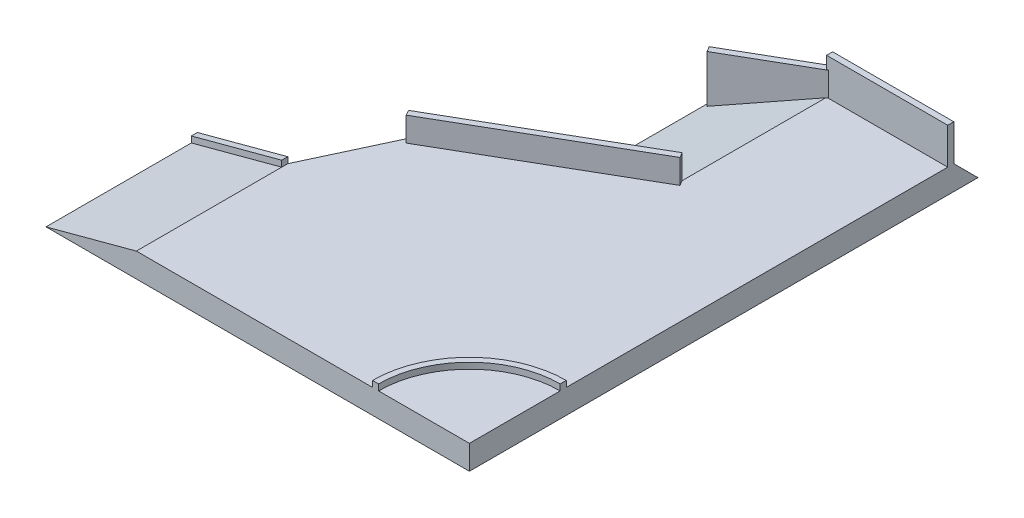
from build123d import *

# Parameters (mm, degrees)
EXTRUDE_1_DEPTH              = 400
EXTRUDE_2_DEPTH              = 100
SKETCH_3_W                   = 2000
SKETCH_3_H                   = 100
EXTRUDE_3_DEPTH              = 600
EXTRUDE_4_DEPTH              = 400
EXTRUDE_5_DEPTH              = 2500
EXTRUDE_6_DEPTH              = 100
EXTRUDE_7_REACH              = 6699.625
EXTRUDE_8_REACH              = 9240.058
EXTRUDE_10_REACH             = 8119.853
EXTRUDE_11_DEPTH             = 1492.820323
EXTRUDE_11_DIRECTION_2_REACH = 8492.6
SKETCH_12_W                  = 1492.820323027
SKETCH_12_H                  = 800
EXTRUDE_12_DEPTH             = 100


with BuildPart() as part:
    # 草图1 → 凸台-拉伸1 (new body)
    with BuildSketch(Plane(origin=(0, 0, 0), x_dir=(1, 0, 0), z_dir=(0, 1, 0))):
        Polygon((-2750, -1500), (-2116.072607389, -140.538319445), (750, 1514.189471948), (750, 4000), (2750, 4000), (2750, -4000), (-2750, -4000), align=None)
    extrude(amount=EXTRUDE_1_DEPTH)

    # 草图2 → 凸台-拉伸2 (add)
    with BuildSketch(Plane(origin=(0, 400, 0), x_dir=(1, 0, 0), z_dir=(0, 1, 0))):
        with BuildLine():
            Line((1150, -4000), (1250, -4000))
            ThreePointArc((1250, -4000), (1689.33982822, -2939.33982822), (2750, -2500))
            Line((2750, -2500), (2750, -2400))
            ThreePointArc((2750, -2400), (1618.629150102, -2868.629150102), (1150, -4000))
        make_face()
    extrude(amount=EXTRUDE_2_DEPTH)

    # 草图3 → 凸台-拉伸3 (add)
    with BuildSketch(Plane(origin=(0, 400, 0), x_dir=(1, 0, 0), z_dir=(0, 1, 0))):
        with Locations((1750, 3950)):
            Rectangle(SKETCH_3_W, SKETCH_3_H)
    extrude(amount=EXTRUDE_3_DEPTH)

    # 草图4 → 凸台-拉伸4 (add)
    with BuildSketch(Plane(origin=(0, 400, 0), x_dir=(1, 0, 0), z_dir=(0, 1, 0))):
        Polygon((750, 1514.189471948), (-2116.072607389, -140.538319445), (-2066.072607389, -227.140859823), (800, 1427.58693157), align=None)
    extrude(amount=EXTRUDE_4_DEPTH)

    # 草图5 → 凸台-拉伸5 (add)
    with BuildSketch(Plane.XY.offset(4000)):
        Polygon((-2750, 400), (-2750, 0), (-4242.820323028, 0), align=None)
    extrude(amount=-EXTRUDE_5_DEPTH)

    # 草图6 → 凸台-拉伸6 (add)
    with BuildSketch(Plane(origin=(0, 0, 1500), x_dir=(-1, 0, 0), z_dir=(0, 0, -1))):
        Polygon((2750, 400), (4242.820323028, 0), (4242.820323028, 100), (2750, 500), align=None)
    extrude(amount=-EXTRUDE_6_DEPTH)

    # 凸台-拉伸7: up to this plane
    extrude_7_end = Plane(origin=(750, 400, -1514.189471948), z_dir=(1, 0, 0))
    # 草图7 → 凸台-拉伸7 (add, up to the surface)
    with BuildSketch(Plane(origin=(-1647.909332964, 0, 951.420896987), x_dir=(0.4999999999999981, 0, 0.8660254037844398), z_dir=(-0.8660254037844398, 0, 0.49999999999999817)), mode=Mode.PRIVATE) as extrude_7_sk1:
        Polygon((-936.32654885, 0), (-1336.32654885, 0), (-936.32654885, 400), align=None)
    extrude_7_tool1 = split(extrude(extrude_7_sk1.sketch, amount=-EXTRUDE_7_REACH, mode=Mode.PRIVATE), bisect_by=extrude_7_end, keep=Keep.BOTH, mode=Mode.PRIVATE)
    add(extrude_7_tool1.solids().sort_by_distance((-2182.739274, 133.333333, 25.068266))[0])

    # 凸台-拉伸8: up to this plane
    extrude_8_end = Plane(origin=(499800, 0, -290102.721526381), z_dir=(-0.3535533905932706, 0.7071067811865511, -0.6123724356957922))
    # 草图8 → 凸台-拉伸8 (add, up to the surface)
    with BuildSketch(Plane(origin=(-1544.550807569, 0, -2675.240473581), x_dir=(0, -1, 0), z_dir=(0.49999999999999495, 0, 0.8660254037844416)), mode=Mode.PRIVATE) as extrude_8_sk1:
        Polygon((0, 2649.519052838), (-400, 2649.519052838), (0, 1156.698729811), align=None)
    extrude_8_tool1 = split(extrude(extrude_8_sk1.sketch, amount=EXTRUDE_8_REACH, dir=(0, 0, 1), mode=Mode.PRIVATE), bisect_by=extrude_8_end, keep=Keep.BOTH, mode=Mode.PRIVATE)
    add(extrude_8_tool1.solids().sort_by_distance((319.059892, 133.333333, -3751.196613))[0])

    # 凸台-拉伸10: up to this plane
    extrude_10_end = Plane(origin=(1699.759526419, 0, -455.449192431), z_dir=(-0.96592582628907, 0, 0.25881904510251463))
    # 草图9 → 凸台-拉伸10 (add, up to the surface)
    with BuildSketch(Plane(origin=(2750, 0, 0), x_dir=(0, 0, -1), z_dir=(1, 0, 0)), mode=Mode.PRIVATE) as extrude_10_sk1:
        Polygon((4000, 0), (4400, 0), (4000, 400), align=None)
    extrude_10_tool1 = split(extrude(extrude_10_sk1.sketch, amount=-EXTRUDE_10_REACH, mode=Mode.PRIVATE), bisect_by=extrude_10_end, keep=Keep.BOTH, mode=Mode.PRIVATE)
    add(extrude_10_tool1.solids().sort_by_distance((2750, 133.333333, -4133.333333))[0])

    # 草图11 → 凸台-拉伸11 (add)
    with BuildSketch(Plane(origin=(2294.550807569, 0, -1324.759526419), x_dir=(0, 1, 0), z_dir=(-0.8660254037844416, 0, 0.49999999999999506))):
        Polygon((400, 3089.101615138), (0, 3089.101615138), (0, 3489.101615138), align=None)
    extrude(amount=EXTRUDE_11_DEPTH)

    # 凸台-拉伸11 direction 2: up to this face of the body (flat: up to its plane)
    extrude_11_direction_2_end = Plane(part.part.faces().sort_by_distance((714.273441009, 133.333333333, -4133.333333333))[0])
    # 草图11 → 凸台-拉伸11 direction 2 (add, up to the picked face)
    with BuildSketch(Plane(origin=(2294.550807569, 0, -1324.759526419), x_dir=(0, 1, 0), z_dir=(-0.8660254037844416, 0, 0.49999999999999506)), mode=Mode.PRIVATE) as extrude_11_direction_2_sk1:
        Polygon((400, 3089.101615138), (0, 3089.101615138), (0, 3489.101615138), align=None)
    extrude_11_direction_2_tool1 = split(extrude(extrude_11_direction_2_sk1.sketch, amount=-EXTRUDE_11_DIRECTION_2_REACH, mode=Mode.PRIVATE), bisect_by=extrude_11_direction_2_end, keep=Keep.BOTH, mode=Mode.PRIVATE)
    add(extrude_11_direction_2_tool1.solids().sort_by(Axis((683.333333, 133.333333, -4115.470054), (0.8660254037844416, 0, -0.49999999999999506)))[0])

    # 草图12 → 凸台-拉伸12 (add)
    with BuildSketch(Plane(origin=(-1544.550807569, 0, -2675.240473581), x_dir=(0.8660254037844417, 0, -0.49999999999999495), z_dir=(0.49999999999999495, 0, 0.8660254037844417))):
        with Locations((1903.108891325, 400)):
            Rectangle(SKETCH_12_W, SKETCH_12_H)
    extrude(amount=EXTRUDE_12_DEPTH)


solid = part.part
